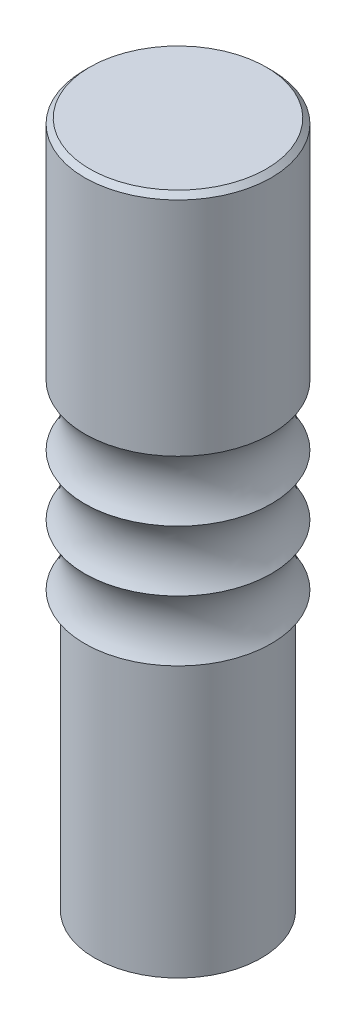
from build123d import *

# Parameters (mm, degrees)
ESQUISSE1_R        = 16.5
BOSS_EXTRU_1_DEPTH = 55
CHANFREIN1_SIZE    = 1


with BuildPart() as part:
    # Esquisse1 → Boss.-Extru.1 (new body)
    with BuildSketch(Plane(origin=(0, 0, 0), x_dir=(1, 0, 0), z_dir=(0, 1, 0))):
        with Locations(Location((0, 0, 0), (0, 0, 270))):  # turned: the seam where the file's is
            Circle(ESQUISSE1_R)
    extrude(amount=BOSS_EXTRU_1_DEPTH)

    # Esquisse5 → Révolution1 (revolve)
    with BuildSketch(Plane.XY, mode=Mode.PRIVATE) as r_volution1_sk:
        with BuildLine():
            Line((0, 55), (18.5, 55))
            ThreePointArc((18.5, 55), (16.5, 61), (18.5, 67))
            ThreePointArc((18.5, 67), (16.5, 73), (18.5, 79))
            ThreePointArc((18.5, 79), (16.5, 85), (18.5, 91))
            Line((18.5, 91), (18.5, 136))
            Line((18.5, 136), (0, 136))
            Line((0, 136), (0, 55))
        make_face()
    revolve(r_volution1_sk.sketch.rotate(Axis((0, 136, 0), (0, -1, 0)), 180), axis=Axis((0, 136, 0), (0, -1, 0)))  # turned: the seam where the file's is

    # Chanfrein1
    chanfrein1_edges = [part.edges().sort_by_distance(p)[0] for p in [
        (18.5, 136, 0),
    ]]
    chamfer(chanfrein1_edges, length=CHANFREIN1_SIZE)


solid = part.part
